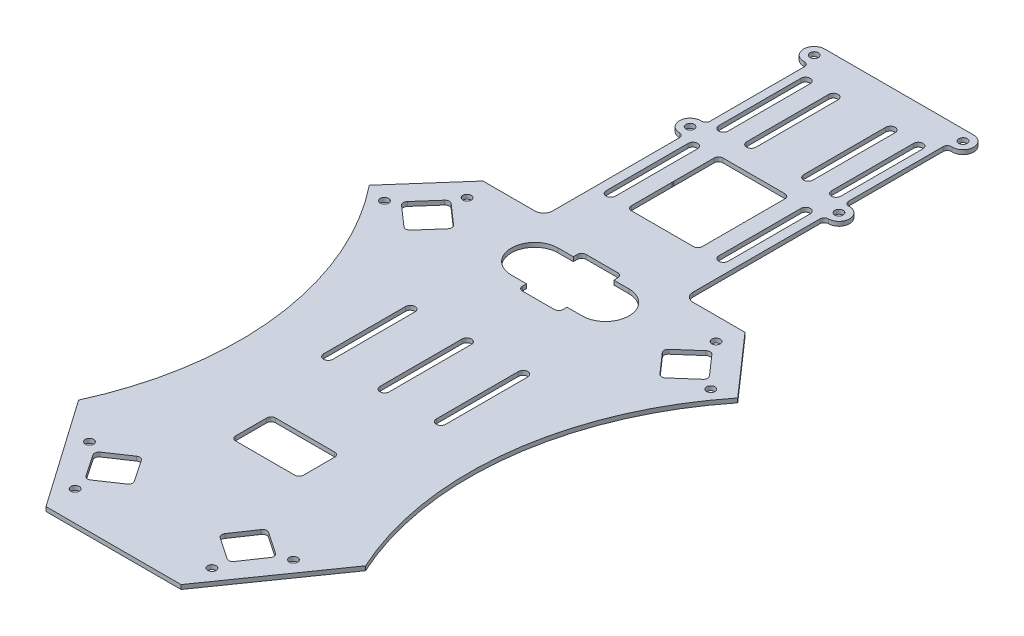
from build123d import *

# Parameters (mm, degrees)
BOSS_EXTRUDE1_DEPTH = 1.53
SKETCH2_R           = 1.5
CUT_EXTRUDE1_DEPTH  = 1.53


with BuildPart() as part:
    # Sketch1 → Boss-Extrude1 (new body)
    with BuildSketch(Plane(origin=(0, 0, 0), x_dir=(1, 0, 0), z_dir=(0, 1, 0))):
        with BuildLine():
            Line((-24.225, -100.313959073), (24.225, -100.313959073))
            Line((24.225, -100.313959073), (51.475, -61.381343132))
            ThreePointArc((51.475, -61.381343132), (41.92219647, 0.128398889), (66.075, 57.498656868))
            Line((66.075, 57.498656868), (47, 79.196040927))
            Line((47, 79.196040927), (28.38, 79.196040927))
            ThreePointArc((28.38, 79.196040927), (26.131400436, 80.127441362), (25.2, 82.376040927))
            Line((25.2, 82.376040927), (25.2, 127.896040927))
            ThreePointArc((25.2, 127.896040927), (25.639339828, 128.956701098), (26.7, 129.396040927))
            ThreePointArc((26.7, 129.396040927), (30.497925704, 133.321581153), (26.449056604, 136.987746006))
            ThreePointArc((26.449056604, 136.987746006), (25.324959734, 137.389349578), (24.85, 138.484471696))
            Line((24.85, 138.484471696), (24.85, 172.407610157))
            ThreePointArc((24.85, 172.407610157), (25.324959734, 173.502732275), (26.449056604, 173.904335847))
            ThreePointArc((26.449056604, 173.904335847), (30.497925704, 177.5705007), (26.7, 181.496040927))
            Line((26.7, 181.496040927), (-26.7, 181.496040927))
            ThreePointArc((-26.7, 181.496040927), (-30.497925704, 177.5705007), (-26.449056604, 173.904335847))
            ThreePointArc((-26.449056604, 173.904335847), (-25.324959734, 173.502732275), (-24.85, 172.407610157))
            Line((-24.85, 172.407610157), (-24.85, 138.484471696))
            ThreePointArc((-24.85, 138.484471696), (-25.324959734, 137.389349578), (-26.449056604, 136.987746006))
            ThreePointArc((-26.449056604, 136.987746006), (-30.497925704, 133.321581153), (-26.7, 129.396040927))
            ThreePointArc((-26.7, 129.396040927), (-25.639339828, 128.956701098), (-25.2, 127.896040927))
            Line((-25.2, 127.896040927), (-25.2, 82.376040927))
            ThreePointArc((-25.2, 82.376040927), (-26.131400436, 80.127441362), (-28.38, 79.196040927))
            Line((-28.38, 79.196040927), (-47, 79.196040927))
            Line((-47, 79.196040927), (-66.075, 57.498656868))
            ThreePointArc((-66.075, 57.498656868), (-41.92219647, 0.128398889), (-51.475, -61.381343132))
            Line((-51.475, -61.381343132), (-24.225, -100.313959073))
        make_face()
        with BuildLine():
            Line((-26.611630339, -83.593554115), (-31.856126021, -75.840821368))
            ThreePointArc((-31.856126021, -75.840821368), (-32.097277956, -74.663642225), (-31.43540677, -73.660730702))
            Line((-31.43540677, -73.660730702), (-23.682674023, -68.41623502))
            ThreePointArc((-23.682674023, -68.41623502), (-22.50549488, -68.175083085), (-21.502583357, -68.836954272))
            Line((-21.502583357, -68.836954272), (-16.258087675, -76.589687018))
            ThreePointArc((-16.258087675, -76.589687018), (-16.016935741, -77.766866161), (-16.678806927, -78.769777684))
            Line((-16.678806927, -78.769777684), (-24.431539674, -84.014273366))
            ThreePointArc((-24.431539674, -84.014273366), (-25.608718816, -84.255425301), (-26.611630339, -83.593554115))
        make_face(mode=Mode.SUBTRACT)
        with BuildLine():
            ThreePointArc((-21.9, 26.376040927), (-20.22, 28.056040927), (-18.54, 26.376040927))
            Line((-18.54, 26.376040927), (-18.54, -3.083959073))
            ThreePointArc((-18.54, -3.083959073), (-20.22, -4.763959073), (-21.9, -3.083959073))
            Line((-21.9, -3.083959073), (-21.9, 26.376040927))
        make_face(mode=Mode.SUBTRACT)
        with BuildLine():
            ThreePointArc((26.611630339, -83.593554115), (25.608718816, -84.255425301), (24.431539674, -84.014273366))
            Line((24.431539674, -84.014273366), (16.678806927, -78.769777684))
            ThreePointArc((16.678806927, -78.769777684), (16.016935741, -77.766866161), (16.258087675, -76.589687018))
            Line((16.258087675, -76.589687018), (21.502583357, -68.836954272))
            ThreePointArc((21.502583357, -68.836954272), (22.50549488, -68.175083085), (23.682674023, -68.41623502))
            Line((23.682674023, -68.41623502), (31.43540677, -73.660730702))
            ThreePointArc((31.43540677, -73.660730702), (32.097277956, -74.663642225), (31.856126021, -75.840821368))
            Line((31.856126021, -75.840821368), (26.611630339, -83.593554115))
        make_face(mode=Mode.SUBTRACT)
        with BuildLine():
            Line((-10.615, -31.603959073), (10.615, -31.603959073))
            ThreePointArc((10.615, -31.603959073), (11.725157646, -32.063801427), (12.185, -33.173959073))
            Line((12.185, -33.173959073), (12.185, -44.353959073))
            ThreePointArc((12.185, -44.353959073), (11.725157646, -45.46411672), (10.615, -45.923959073))
            Line((10.615, -45.923959073), (-10.615, -45.923959073))
            ThreePointArc((-10.615, -45.923959073), (-11.725157646, -45.46411672), (-12.185, -44.353959073))
            Line((-12.185, -44.353959073), (-12.185, -33.173959073))
            ThreePointArc((-12.185, -33.173959073), (-11.725157646, -32.063801427), (-10.615, -31.603959073))
        make_face(mode=Mode.SUBTRACT)
        with BuildLine():
            ThreePointArc((-1.68, 26.376040927), (0, 28.056040927), (1.68, 26.376040927))
            Line((1.68, 26.376040927), (1.68, -3.083959073))
            ThreePointArc((1.68, -3.083959073), (0, -4.763959073), (-1.68, -3.083959073))
            Line((-1.68, -3.083959073), (-1.68, 26.376040927))
        make_face(mode=Mode.SUBTRACT)
        with BuildLine():
            Line((18.54, -3.083959073), (18.54, 26.376040927))
            ThreePointArc((18.54, 26.376040927), (20.22, 28.056040927), (21.9, 26.376040927))
            Line((21.9, 26.376040927), (21.9, -3.083959073))
            ThreePointArc((21.9, -3.083959073), (20.22, -4.763959073), (18.54, -3.083959073))
        make_face(mode=Mode.SUBTRACT)
        with BuildLine():
            ThreePointArc((-54.040190621, 57.042105422), (-54.570340289, 58.120458945), (-54.182701627, 59.257842459))
            Line((-54.182701627, 59.257842459), (-47.936613015, 66.362627962))
            ThreePointArc((-47.936613015, 66.362627962), (-46.858259493, 66.892777631), (-45.720875979, 66.505138968))
            Line((-45.720875979, 66.505138968), (-38.616090475, 60.259050356))
            ThreePointArc((-38.616090475, 60.259050356), (-38.085940807, 59.180696834), (-38.473579469, 58.04331332))
            Line((-38.473579469, 58.04331332), (-44.719668081, 50.938527817))
            ThreePointArc((-44.719668081, 50.938527817), (-45.798021603, 50.408378148), (-46.935405117, 50.796016811))
            Line((-46.935405117, 50.796016811), (-54.040190621, 57.042105422))
        make_face(mode=Mode.SUBTRACT)
        with BuildLine():
            ThreePointArc((-21.9, 127.716040927), (-20.22, 129.396040927), (-18.54, 127.716040927))
            Line((-18.54, 127.716040927), (-18.54, 98.256040927))
            ThreePointArc((-18.54, 98.256040927), (-20.22, 96.576040927), (-21.9, 98.256040927))
            Line((-21.9, 98.256040927), (-21.9, 127.716040927))
        make_face(mode=Mode.SUBTRACT)
        with BuildLine():
            ThreePointArc((-21.9, 168.127746006), (-20.22, 169.807746006), (-18.54, 168.127746006))
            Line((-18.54, 168.127746006), (-18.54, 138.667746006))
            ThreePointArc((-18.54, 138.667746006), (-20.22, 136.987746006), (-21.9, 138.667746006))
            Line((-21.9, 138.667746006), (-21.9, 168.127746006))
        make_face(mode=Mode.SUBTRACT)
        with BuildLine():
            ThreePointArc((-11.9, 168.127746006), (-10.22, 169.807746006), (-8.54, 168.127746006))
            Line((-8.54, 168.127746006), (-8.54, 138.667746006))
            ThreePointArc((-8.54, 138.667746006), (-10.22, 136.987746006), (-11.9, 138.667746006))
            Line((-11.9, 138.667746006), (-11.9, 168.127746006))
        make_face(mode=Mode.SUBTRACT)
        with BuildLine():
            ThreePointArc((-12.7, 55.076040927), (-21.1, 63.476040927), (-12.7, 71.876040927))
            Line((-12.7, 71.876040927), (-7.265, 71.876040927))
            Line((-7.265, 71.876040927), (-7.265, 73.306040927))
            ThreePointArc((-7.265, 73.306040927), (-6.805157646, 74.416198573), (-5.695, 74.876040927))
            Line((-5.695, 74.876040927), (5.695, 74.876040927))
            ThreePointArc((5.695, 74.876040927), (6.805157646, 74.416198573), (7.265, 73.306040927))
            Line((7.265, 73.306040927), (7.265, 71.876040927))
            Line((7.265, 71.876040927), (12.7, 71.876040927))
            ThreePointArc((12.7, 71.876040927), (21.1, 63.476040927), (12.7, 55.076040927))
            Line((12.7, 55.076040927), (7.265, 55.076040927))
            Line((7.265, 55.076040927), (7.265, 53.646040927))
            ThreePointArc((7.265, 53.646040927), (6.805157646, 52.53588328), (5.695, 52.076040927))
            Line((5.695, 52.076040927), (-5.695, 52.076040927))
            ThreePointArc((-5.695, 52.076040927), (-6.805157646, 52.53588328), (-7.265, 53.646040927))
            Line((-7.265, 53.646040927), (-7.265, 55.076040927))
            Line((-7.265, 55.076040927), (-12.7, 55.076040927))
        make_face(mode=Mode.SUBTRACT)
        with BuildLine():
            ThreePointArc((54.182701627, 59.257842459), (54.570340289, 58.120458945), (54.040190621, 57.042105422))
            Line((54.040190621, 57.042105422), (46.935405117, 50.796016811))
            ThreePointArc((46.935405117, 50.796016811), (45.798021603, 50.408378148), (44.719668081, 50.938527817))
            Line((44.719668081, 50.938527817), (38.473579469, 58.04331332))
            ThreePointArc((38.473579469, 58.04331332), (38.085940807, 59.180696834), (38.616090475, 60.259050356))
            Line((38.616090475, 60.259050356), (45.720875979, 66.505138968))
            ThreePointArc((45.720875979, 66.505138968), (46.858259493, 66.892777631), (47.936613015, 66.362627962))
            Line((47.936613015, 66.362627962), (54.182701627, 59.257842459))
        make_face(mode=Mode.SUBTRACT)
        with BuildLine():
            Line((-11.13, 129.396040927), (11.13, 129.396040927))
            ThreePointArc((11.13, 129.396040927), (12.240157646, 128.936198573), (12.7, 127.826040927))
            Line((12.7, 127.826040927), (12.7, 113.506040927))
            ThreePointArc((12.7, 113.506040927), (12.677687573, 113.242292605), (12.611384488, 112.986040927))
            ThreePointArc((12.611384488, 112.986040927), (12.677687573, 112.729789248), (12.7, 112.466040927))
            Line((12.7, 112.466040927), (12.7, 98.146040927))
            ThreePointArc((12.7, 98.146040927), (12.240157646, 97.03588328), (11.13, 96.576040927))
            Line((11.13, 96.576040927), (-11.13, 96.576040927))
            ThreePointArc((-11.13, 96.576040927), (-12.240157646, 97.03588328), (-12.7, 98.146040927))
            Line((-12.7, 98.146040927), (-12.7, 112.466040927))
            ThreePointArc((-12.7, 112.466040927), (-12.677687573, 112.729789248), (-12.611384488, 112.986040927))
            ThreePointArc((-12.611384488, 112.986040927), (-12.677687573, 113.242292605), (-12.7, 113.506040927))
            Line((-12.7, 113.506040927), (-12.7, 127.826040927))
            ThreePointArc((-12.7, 127.826040927), (-12.240157646, 128.936198573), (-11.13, 129.396040927))
        make_face(mode=Mode.SUBTRACT)
        with BuildLine():
            Line((18.54, 98.256040927), (18.54, 127.716040927))
            ThreePointArc((18.54, 127.716040927), (20.22, 129.396040927), (21.9, 127.716040927))
            Line((21.9, 127.716040927), (21.9, 98.256040927))
            ThreePointArc((21.9, 98.256040927), (20.22, 96.576040927), (18.54, 98.256040927))
        make_face(mode=Mode.SUBTRACT)
        with BuildLine():
            Line((8.54, 138.667746006), (8.54, 168.127746006))
            ThreePointArc((8.54, 168.127746006), (10.22, 169.807746006), (11.9, 168.127746006))
            Line((11.9, 168.127746006), (11.9, 138.667746006))
            ThreePointArc((11.9, 138.667746006), (10.22, 136.987746006), (8.54, 138.667746006))
        make_face(mode=Mode.SUBTRACT)
        with BuildLine():
            Line((18.54, 138.667746006), (18.54, 168.127746006))
            ThreePointArc((18.54, 168.127746006), (20.22, 169.807746006), (21.9, 168.127746006))
            Line((21.9, 168.127746006), (21.9, 138.667746006))
            ThreePointArc((21.9, 138.667746006), (20.22, 136.987746006), (18.54, 138.667746006))
        make_face(mode=Mode.SUBTRACT)
    extrude(amount=BOSS_EXTRUDE1_DEPTH)

    # Sketch2 → Cut-Extrude1 (cut)
    with BuildSketch(Plane(origin=(0, 1.53, 0), x_dir=(1, 0, 0), z_dir=(0, 1, 0))):
        with Locations((-26.7, 177.696040927)):
            Circle(SKETCH2_R)
        with Locations((26.7, 177.696040927)):
            Circle(SKETCH2_R)
        with Locations((-26.7, 133.196040927)):
            Circle(SKETCH2_R)
        with Locations((26.7, 133.196040927)):
            Circle(SKETCH2_R)
        with Locations((-58.524424259, 55.392079629)):
            Circle(SKETCH2_R)
        with Locations((-44.658899856, 71.163802205)):
            Circle(SKETCH2_R)
        with Locations((-36.572543301, -72.374529398)):
            Circle(SKETCH2_R)
        with Locations((-24.530673748, -89.578987473)):
            Circle(SKETCH2_R)
        with Locations((36.677447237, -72.446717436)):
            Circle(SKETCH2_R)
        with Locations((24.635577684, -89.651175511)):
            Circle(SKETCH2_R)
        with Locations((58.524424259, 55.392079629)):
            Circle(SKETCH2_R)
        with Locations((44.658899856, 71.163802205)):
            Circle(SKETCH2_R)
    extrude(amount=-CUT_EXTRUDE1_DEPTH, mode=Mode.SUBTRACT)


solid = part.part
